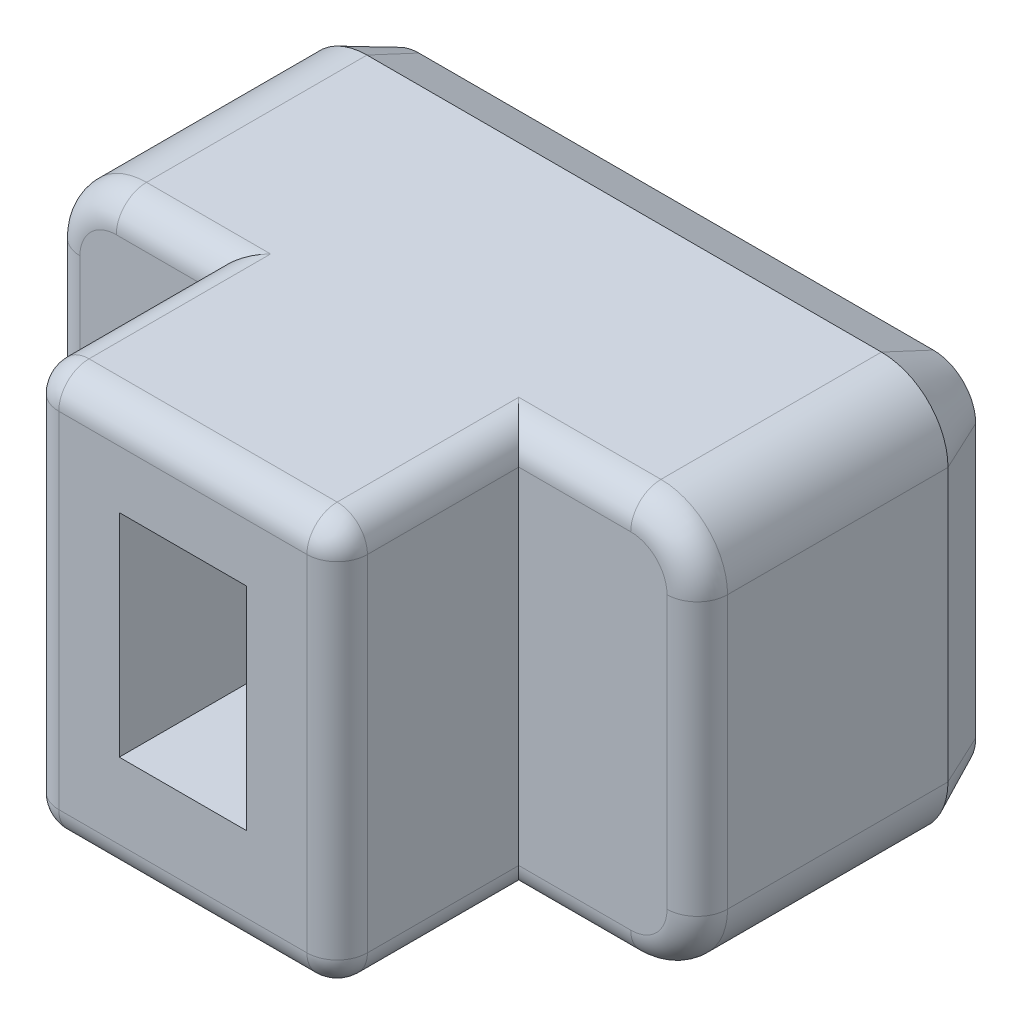
from build123d import *

# Parameters (mm, degrees)
BOSS_EXTRU_1_DEPTH      = 8
ESQUISSE3_W             = 2.1
ESQUISSE3_H             = 3.5
ENL_V_MAT_EXTRU_1_DEPTH = 3
ESQUISSE4_OUTSIDE_W     = 15.69
ESQUISSE4_OUTSIDE_H     = 11.69
ESQUISSE4_OUTSIDE_W_2   = 5.1
ESQUISSE4_OUTSIDE_H_2   = 6.7
ENL_V_MAT_EXTRU_2_DEPTH = 3
CONG_1_R                = 0.5
CHANFREIN1_SIZE         = 0.4
CHANFREIN1_SIZE2        = 0.857802768
ENL_V_MAT_EXTRU_3_DEPTH = 0.2
BOSS_EXTRU_2_DEPTH      = 0.2
BOSS_EXTRU_2_2_DEPTH    = 0.2
BOSS_EXTRU_2_3_DEPTH    = 0.2


with BuildPart() as part:
    # Esquisse2 → Boss.-Extru.1 (new body)
    with BuildSketch(Plane.XY):
        with BuildLine():
            Line((1.1, 0), (9.6, 0))
            ThreePointArc((9.6, 0), (10.377817459, 0.322182541), (10.7, 1.1))
            Line((10.7, 1.1), (10.7, 5.6))
            ThreePointArc((10.7, 5.6), (10.377817459, 6.377817459), (9.6, 6.7))
            Line((9.6, 6.7), (1.1, 6.7))
            ThreePointArc((1.1, 6.7), (0.322182541, 6.377817459), (0, 5.6))
            Line((0, 5.6), (0, 1.1))
            ThreePointArc((0, 1.1), (0.322182541, 0.322182541), (1.1, 0))
        make_face()
    extrude(amount=BOSS_EXTRU_1_DEPTH)

    # Esquisse3 → Enlèv. mat.-Extru.1 (cut)
    with BuildSketch(Plane.XY.offset(8)):
        with Locations((5.2, 3.5)):
            Rectangle(ESQUISSE3_W, ESQUISSE3_H)
    extrude(amount=-ENL_V_MAT_EXTRU_1_DEPTH, mode=Mode.SUBTRACT)

    # Esquisse4 outside → Enlèv. mat.-Extru.2 (cut)
    with BuildSketch(Plane.XY.offset(8)):
        with Locations((5.35, 3.35)):
            Rectangle(ESQUISSE4_OUTSIDE_W, ESQUISSE4_OUTSIDE_H)
        with Locations((5.2, 3.35)):
            Rectangle(ESQUISSE4_OUTSIDE_W_2, ESQUISSE4_OUTSIDE_H_2, mode=Mode.SUBTRACT)
    extrude(amount=-ENL_V_MAT_EXTRU_2_DEPTH, mode=Mode.SUBTRACT)

    # Congé1
    cong_1_edges = [part.edges().sort_by_distance(p)[0] for p in [
        (8.675, 0, 5),
        (10.377817459, 0.322182541, 5),
        (10.7, 3.35, 5),
        (10.377817459, 6.377817459, 5),
        (1.875, 6.7, 5),
        (0.322182541, 6.377817459, 5),
        (1.875, 0, 5),
        (0.322182541, 0.322182541, 5),
        (7.75, 6.7, 6.5),
        (2.65, 6.7, 6.5),
        (7.75, 0, 6.5),
        (2.65, 0, 6.5),
        (2.65, 3.35, 8),
        (5.2, 6.7, 8),
        (7.75, 3.35, 8),
        (5.2, 0, 8),
        (8.675, 6.7, 5),
        (0, 3.35, 5),
    ]]
    fillet(cong_1_edges, radius=CONG_1_R)

    # Chanfrein1
    chanfrein1_edges = [part.edges().sort_by_distance(p)[0] for p in [
        (5.35, 0, 0),
        (10.377817459, 0.322182541, 0),
        (0.322182541, 0.322182541, 0),
        (10.7, 3.35, 0),
        (0, 3.35, 0),
        (10.377817459, 6.377817459, 0),
        (0.322182541, 6.377817459, 0),
        (5.35, 6.7, 0),
    ]]
    chanfrein1_side = [part.faces().sort_by_distance(p)[0] for p in [
        (5.35, 3.35, 0),
    ]]
    chamfer(chanfrein1_edges, length=CHANFREIN1_SIZE, length2=CHANFREIN1_SIZE2, reference=chanfrein1_side[0])

    # Esquisse5 → Enlèv. mat.-Extru.3 (cut)
    # profile 1 of 3: a face of its own
    with BuildSketch(Plane.XY):
        with BuildLine():
            add(Edge.make_bspline(
                [(4.369883856, 3.345323967), (4.368813227, 3.410220828), (4.366709631, 3.537731584), (4.346611401, 3.724706106), (4.315397475, 3.903896521), (4.270277148, 4.074043652), (4.214340316, 4.234867614), (4.145398671, 4.384037783), (4.067839771, 4.523027282), (3.977033045, 4.64884802), (3.877234147, 4.763460778), (3.766783654, 4.86465433), (3.646348249, 4.952148406), (3.516567888, 5.026128704), (3.377499423, 5.085153386), (3.23014263, 5.128172016), (3.074642666, 5.153177552), (2.968475155, 5.156439228), (2.914392271, 5.158100761)],
                knots=[0, 0, 0, 0, 1.195144352, 2.348245511, 3.460097322, 4.542876954, 5.587478219, 6.592632067, 7.566624142, 8.51487101, 9.445639952, 10.361865309, 11.268098707, 12.182468178, 13.107953852, 14.044738146, 15.003968361, 16, 16, 16, 16], degree=3))
            add(Edge.make_bspline(
                [(2.914392271, 5.158100761), (2.858503939, 5.156442095), (2.749000584, 5.15319223), (2.58911106, 5.128325275), (2.438563184, 5.085456576), (2.297551178, 5.026093738), (2.166331241, 4.952363862), (2.045054972, 4.864856392), (1.934590737, 4.763621498), (1.835308413, 4.649088668), (1.746580653, 4.522455836), (1.668059352, 4.384679404), (1.602624479, 4.234346876), (1.546419096, 4.074225408), (1.503890325, 3.903618271), (1.471688338, 3.724799052), (1.453085955, 3.537667095), (1.45077621, 3.41020789), (1.44960042, 3.345323967)],
                knots=[0, 0, 0, 0, 1.024070166, 2.006485348, 2.956709171, 3.886215782, 4.804181762, 5.709643439, 6.621212706, 7.544135401, 8.482081823, 9.451124249, 10.445335459, 11.483063107, 12.557965142, 13.664166725, 14.810929153, 16, 16, 16, 16], degree=3))
            add(Edge.make_bspline(
                [(1.44960042, 3.345323967), (1.450681706, 3.27991297), (1.452802251, 3.15163338), (1.472673532, 2.963545193), (1.504850674, 2.783610957), (1.550947225, 2.612865811), (1.606490699, 2.451322043), (1.675624603, 2.301941529), (1.753431271, 2.162884409), (1.843537024, 2.03675055), (1.943302105, 1.922293635), (2.053460716, 1.821322753), (2.174248749, 1.733720921), (2.304118559, 1.659234354), (2.44361916, 1.599706154), (2.591829693, 1.558097246), (2.748179984, 1.532703821), (2.855134899, 1.52952171), (2.909742138, 1.527897041)],
                knots=[0, 0, 0, 0, 1.200815508, 2.354957547, 3.468772541, 4.553900434, 5.599644995, 6.601592885, 7.572478393, 8.521561906, 9.44266753, 10.355970568, 11.259313516, 12.177237418, 13.099771236, 14.036815551, 14.997670343, 16, 16, 16, 16], degree=3))
            add(Edge.make_bspline(
                [(2.909742138, 1.527897041), (2.965380049, 1.529517802), (3.074129715, 1.532685735), (3.2328265, 1.557982475), (3.382777287, 1.599763578), (3.523547932, 1.658838184), (3.6537362, 1.733766772), (3.774577817, 1.821294574), (3.884614437, 1.922361439), (3.984625613, 2.036278266), (4.072817135, 2.163241667), (4.150337738, 2.301721239), (4.217282836, 2.451617532), (4.272956083, 2.612606076), (4.315623289, 2.783922075), (4.347785722, 2.963532044), (4.366426284, 3.151688757), (4.368716047, 3.279922883), (4.369883856, 3.345323967)],
                knots=[0, 0, 0, 0, 1.019197321, 1.992119517, 2.93636417, 3.865739406, 4.781791275, 5.683291926, 6.594732354, 7.513959455, 8.45564896, 9.422226809, 10.418223395, 11.460277027, 12.539615728, 13.65032206, 14.80163346, 16, 16, 16, 16], degree=3))
        make_face()
        with BuildLine():
            add(Edge.make_bspline(
                [(3.96997243, 3.345323967), (3.96884926, 3.288201422), (3.966670176, 3.177376975), (3.952204476, 3.016195737), (3.926755898, 2.86537907), (3.891193452, 2.725247869), (3.847212338, 2.595729132), (3.794264836, 2.477698567), (3.734676574, 2.369961728), (3.667419516, 2.273054141), (3.591312135, 2.188749315), (3.510932363, 2.113066055), (3.422442429, 2.050270049), (3.32850521, 1.997817016), (3.229014209, 1.958060987), (3.126151531, 1.927830469), (3.019068777, 1.910779812), (2.946483152, 1.908192501), (2.909742138, 1.906882869)],
                knots=[0, 0, 0, 0, 1.368394323, 2.654845707, 3.872704562, 5.028472935, 6.11467807, 7.145207783, 8.123202714, 9.06064659, 9.963649346, 10.839567245, 11.70000047, 12.555970838, 13.411001045, 14.26108962, 15.119807391, 16, 16, 16, 16], degree=3))
            add(Edge.make_bspline(
                [(2.909742138, 1.906882869), (2.873000037, 1.908189938), (2.800412265, 1.910772185), (2.693345263, 1.927859984), (2.590653538, 1.957883931), (2.491594484, 1.998038294), (2.397758207, 2.050195689), (2.30935871, 2.113371654), (2.228089495, 2.188174045), (2.153024942, 2.273620364), (2.084629, 2.369641486), (2.02529171, 2.47775323), (1.972251, 2.595713296), (1.928296957, 2.725252507), (1.892726596, 2.865377721), (1.867280316, 3.016196126), (1.852813958, 3.177376868), (1.850634968, 3.288201386), (1.849511846, 3.345323967)],
                knots=[0, 0, 0, 0, 0.880286533, 1.739095935, 2.58927522, 3.438665601, 4.294727307, 5.155252347, 6.035821703, 6.93481807, 7.87593048, 8.85402977, 9.884669447, 10.970990489, 12.126882191, 13.344871001, 14.631459659, 16, 16, 16, 16], degree=3))
            add(Edge.make_bspline(
                [(1.849511846, 3.345323967), (1.85054818, 3.402455402), (1.852563896, 3.51357852), (1.868249109, 3.674663508), (1.8932339, 3.825396976), (1.929961093, 3.964898592), (1.974742001, 4.093998133), (2.027353528, 4.212000402), (2.087191546, 4.319590148), (2.155365092, 4.415442486), (2.230149126, 4.500969184), (2.311989392, 4.574847399), (2.399828858, 4.63831116), (2.494354784, 4.689467536), (2.593392372, 4.729794657), (2.696830896, 4.758724401), (2.804252878, 4.776248429), (2.877383718, 4.778151743), (2.914392271, 4.779114933)],
                knots=[0, 0, 0, 0, 1.368396896, 2.661591313, 3.873351804, 5.024673231, 6.112906013, 7.143437663, 8.116034728, 9.057048494, 9.955950632, 10.832263623, 11.692698467, 12.545689711, 13.400721526, 14.249120469, 15.113950864, 16, 16, 16, 16], degree=3))
            add(Edge.make_bspline(
                [(2.914392271, 4.779114933), (2.950883964, 4.77814006), (3.023242204, 4.776207016), (3.129636147, 4.758721508), (3.23231397, 4.729800545), (3.330538759, 4.689415456), (3.424266639, 4.638563902), (3.510742002, 4.574335653), (3.592438045, 4.501002863), (3.667288004, 4.415664638), (3.734511991, 4.31933282), (3.794467771, 4.212021946), (3.847191041, 4.094131189), (3.891075337, 3.9648541), (3.926768538, 3.825280687), (3.95232219, 3.674724962), (3.966624194, 3.513524381), (3.968835362, 3.402445207), (3.96997243, 3.345323967)],
                knots=[0, 0, 0, 0, 0.876608953, 1.738200557, 2.583459865, 3.435601933, 4.286000196, 5.139250103, 6.018494159, 6.920402916, 7.860984094, 8.836834272, 9.870812812, 10.960653102, 12.114272321, 13.330085871, 14.627026132, 16, 16, 16, 16], degree=3))
        make_face(mode=Mode.SUBTRACT)
    # profile 2 of 3: a face of its own
    with BuildSketch(Plane.XY):
        with BuildLine():
            add(Edge.make_bspline(
                [(6.294728852, 3.282547174), (6.318323982, 3.287078083), (6.364650687, 3.295974074), (6.431521219, 3.315538485), (6.494700414, 3.339755345), (6.554370583, 3.368026632), (6.609828754, 3.40200557), (6.661924121, 3.439545463), (6.709125772, 3.482717248), (6.753001082, 3.52916027), (6.792040724, 3.580813296), (6.826023201, 3.637211402), (6.854575667, 3.698508206), (6.879766627, 3.763538022), (6.898895542, 3.833671789), (6.913037581, 3.908273638), (6.920390015, 3.987671197), (6.921782221, 4.042056008), (6.922496788, 4.069969672)],
                knots=[0, 0, 0, 0, 1.039557694, 2.041068696, 3.010926647, 3.966234605, 4.894454937, 5.822675269, 6.741144548, 7.658932823, 8.584860084, 9.538005746, 10.503405151, 11.508592806, 12.553130662, 13.645364566, 14.791454829, 16, 16, 16, 16], degree=3))
            add(Edge.make_bspline(
                [(6.922496788, 4.069969672), (6.920587057, 4.112165235), (6.916657333, 4.198992626), (6.89244803, 4.330616405), (6.849156929, 4.463168248), (6.796064053, 4.570577181), (6.741372392, 4.652167528), (6.695524385, 4.712664159), (6.642460696, 4.769538758), (6.584812988, 4.824935562), (6.51939421, 4.876038129), (6.447006637, 4.922900152), (6.366813298, 4.96390077), (6.309906449, 4.986750483), (6.280778453, 4.998446199)],
                knots=[0, 0, 0, 0, 1.262169839, 2.597214165, 3.987364644, 5.42122417, 6.162619332, 6.922894668, 7.688411995, 8.486304344, 9.311628189, 10.166682751, 11.061609327, 12, 12, 12, 12], degree=3))
            add(Edge.make_bspline(
                [(6.280778453, 4.998446199), (6.232035888, 5.014745638), (6.131215212, 5.048459918), (5.996397012, 5.070022183), (5.879749141, 5.082320352), (5.782237066, 5.088050051), (5.676295187, 5.092061115), (5.602897036, 5.092677682), (5.564657993, 5.092998901)],
                knots=[0, 0, 0, 0, 1.272224456, 2.631509649, 3.371988484, 4.180539351, 5.052095566, 6, 6, 6, 6], degree=3))
            Line((5.564657993, 5.092998901), (4.760185008, 5.092998901))
            Line((4.760185008, 5.092998901), (4.760185008, 1.592998901))
            Line((4.760185008, 1.592998901), (5.536757196, 1.592998901))
            add(Edge.make_bspline(
                [(5.536757196, 1.592998901), (5.57086192, 1.593046739), (5.635729051, 1.593137728), (5.728484047, 1.596536682), (5.812766122, 1.600853351), (5.889819045, 1.607757454), (5.9606124, 1.617158031), (6.026230495, 1.628169622), (6.087680655, 1.640103967), (6.126859617, 1.65064587), (6.1459246, 1.655775695)],
                knots=[0, 0, 0, 0, 1.33236813, 2.534162078, 3.625931115, 4.629299164, 5.555750896, 6.415292179, 7.228860962, 8, 8, 8, 8], degree=3))
            add(Edge.make_bspline(
                [(6.1459246, 1.655775695), (6.19297737, 1.672026596), (6.285658954, 1.704036601), (6.392507025, 1.762662009), (6.470484053, 1.816539226), (6.52254804, 1.862102286), (6.572424814, 1.909109707), (6.616154522, 1.961308913), (6.656059231, 2.01657347), (6.69126254, 2.075520948), (6.720098821, 2.138809848), (6.746545766, 2.204576036), (6.76541619, 2.274637216), (6.77931892, 2.347433716), (6.788104034, 2.42309506), (6.789339513, 2.474433804), (6.789968002, 2.500549831)],
                knots=[0, 0, 0, 0, 1.821757314, 3.588382945, 4.444682079, 5.290872065, 6.121128066, 6.953971212, 7.78163198, 8.617858607, 9.464948542, 10.328232883, 11.212597933, 12.11874062, 13.043003058, 14, 14, 14, 14], degree=3))
            add(Edge.make_bspline(
                [(6.789968002, 2.500549831), (6.788505512, 2.54246582), (6.785627825, 2.624942373), (6.766559593, 2.745775123), (6.73201847, 2.859705204), (6.680273173, 2.965177117), (6.611267631, 3.060640982), (6.540141473, 3.130821955), (6.474104771, 3.179920542), (6.419395221, 3.214764136), (6.359165144, 3.246007761), (6.316575715, 3.263499332), (6.294728852, 3.272471886)],
                knots=[0, 0, 0, 0, 1.279367749, 2.517364972, 3.722042857, 4.899867019, 6.08600249, 7.30154732, 7.932361134, 8.595184829, 9.279379768, 10, 10, 10, 10], degree=3))
            Line((6.294728852, 3.272471886), (6.294728852, 3.282547174))
        make_face()
        with BuildLine():
            add(Edge.make_bspline(
                [(5.715787311, 3.107392169), (5.750425656, 3.106820986), (5.814913324, 3.105757591), (5.905398367, 3.097494652), (5.98439068, 3.083112004), (6.032373974, 3.068064024), (6.05524701, 3.060890841)],
                knots=[0, 0, 0, 0, 1.207490432, 2.248035879, 3.164860632, 4, 4, 4, 4], degree=3))
            add(Edge.make_bspline(
                [(6.05524701, 3.060890841), (6.082814077, 3.049372525), (6.136208783, 3.027062675), (6.20699672, 2.979941455), (6.265553327, 2.922962249), (6.312232565, 2.857429705), (6.34737152, 2.784057471), (6.371575423, 2.704550985), (6.388105544, 2.619030581), (6.389392494, 2.559792983), (6.390056576, 2.52922565)],
                knots=[0, 0, 0, 0, 1.06249791, 2.057954283, 3.008138698, 3.958144825, 4.908952983, 5.892770195, 6.912643363, 8, 8, 8, 8], degree=3))
            add(Edge.make_bspline(
                [(6.390056576, 2.52922565), (6.389053196, 2.498414144), (6.387133577, 2.439467002), (6.371525555, 2.35505087), (6.345331381, 2.279399002), (6.308563018, 2.211703961), (6.259243029, 2.153344234), (6.198449857, 2.10338474), (6.126047708, 2.060791084), (6.071900629, 2.040637065), (6.043621678, 2.03011139)],
                knots=[0, 0, 0, 0, 1.124668362, 2.151663266, 3.121418628, 4.037798149, 4.948624099, 5.893271273, 6.899736026, 8, 8, 8, 8], degree=3))
            add(Edge.make_bspline(
                [(6.043621678, 2.03011139), (6.012005367, 2.021122505), (5.944926681, 2.002051253), (5.833490333, 1.987047748), (5.705327739, 1.979125806), (5.613758997, 1.978008829), (5.564657993, 1.977409884)],
                knots=[0, 0, 0, 0, 0.814629318, 1.728356749, 2.781899107, 4, 4, 4, 4], degree=3))
            Line((5.564657993, 1.977409884), (5.139170836, 1.977409884))
            Line((5.139170836, 1.977409884), (5.139170836, 3.107392169))
            Line((5.139170836, 3.107392169), (5.715787311, 3.107392169))
        make_face(mode=Mode.SUBTRACT)
        with BuildLine():
            Line((5.139170836, 3.491803153), (5.139170836, 4.708587918))
            Line((5.139170836, 4.708587918), (5.597208923, 4.708587918))
            add(Edge.make_bspline(
                [(5.597208923, 4.708587918), (5.649418964, 4.707995588), (5.750403846, 4.706849901), (5.873771201, 4.69583027), (5.965027489, 4.682138419), (6.02723509, 4.6706949), (6.084036015, 4.6564299), (6.119650376, 4.643989873), (6.136624335, 4.638060903)],
                knots=[0, 0, 0, 0, 1.719244745, 3.325370432, 4.073828883, 4.758010158, 5.408062281, 6, 6, 6, 6], degree=3))
            add(Edge.make_bspline(
                [(6.136624335, 4.638060903), (6.170061199, 4.624281189), (6.2345191, 4.597717352), (6.317650883, 4.539865672), (6.386430392, 4.475173905), (6.439766675, 4.402962922), (6.478877925, 4.325135992), (6.50511967, 4.24320503), (6.519957537, 4.158612833), (6.521710691, 4.101542759), (6.522585362, 4.07306976)],
                knots=[0, 0, 0, 0, 1.180851053, 2.276385089, 3.293359184, 4.260951527, 5.19900153, 6.132464837, 7.068262524, 8, 8, 8, 8], degree=3))
            add(Edge.make_bspline(
                [(6.522585362, 4.07306976), (6.521489691, 4.040727732), (6.519355222, 3.977722507), (6.504362378, 3.886376689), (6.476270007, 3.802624164), (6.436060773, 3.725931087), (6.378287487, 3.660423688), (6.307311823, 3.602057466), (6.217222836, 3.555866863), (6.149454673, 3.536314279), (6.11337367, 3.525904127)],
                knots=[0, 0, 0, 0, 1.037774006, 2.021678517, 2.957477969, 3.862483003, 4.779555303, 5.740137878, 6.796808297, 8, 8, 8, 8], degree=3))
            add(Edge.make_bspline(
                [(6.11337367, 3.525904127), (6.088645152, 3.520350924), (6.036203834, 3.508574347), (5.949348637, 3.497901914), (5.846819029, 3.493349413), (5.772625966, 3.492349713), (5.732062776, 3.491803153)],
                knots=[0, 0, 0, 0, 0.792135981, 1.679868331, 2.731526387, 4, 4, 4, 4], degree=3))
            Line((5.732062776, 3.491803153), (5.139170836, 3.491803153))
        make_face(mode=Mode.SUBTRACT)
    # profile 3 of 3: a face of its own
    with BuildSketch(Plane.XY):
        with BuildLine():
            add(Edge.make_bspline(
                [(7.598006089, 2.519150362), (7.598390883, 2.543748085), (7.599132286, 2.591141743), (7.610620119, 2.658611592), (7.626776636, 2.720081012), (7.652432663, 2.774107358), (7.683231965, 2.822524502), (7.717725281, 2.867261442), (7.758878122, 2.906041268), (7.8197572, 2.953064911), (7.907038066, 3.003717061), (8.024126068, 3.049957606), (8.150573171, 3.089057507), (8.237345491, 3.113522336), (8.281575619, 3.125992701)],
                knots=[0, 0, 0, 0, 0.880486965, 1.696478074, 2.446944501, 3.151258593, 3.829523831, 4.502012172, 5.170022751, 5.849803385, 7.256908892, 8.768459035, 10.352798764, 12, 12, 12, 12], degree=3))
            add(Edge.make_bspline(
                [(8.281575619, 3.125992701), (8.341582234, 3.143040851), (8.461391365, 3.177079168), (8.609483565, 3.223336728), (8.723944779, 3.267189913), (8.804655968, 3.305887287), (8.880515462, 3.350604981), (8.952056586, 3.400489678), (9.017720106, 3.458307302), (9.076896499, 3.523894814), (9.129769308, 3.597092218), (9.176205637, 3.678501859), (9.214281445, 3.770574703), (9.239635427, 3.874815211), (9.255246146, 3.990961756), (9.25711968, 4.072239826), (9.25810352, 4.114920956)],
                knots=[0, 0, 0, 0, 1.706742266, 3.407679468, 4.242430161, 5.058020634, 5.853204933, 6.649362358, 7.440579056, 8.241210102, 9.061198638, 9.906297875, 10.800118187, 11.777216625, 12.832761325, 14, 14, 14, 14], degree=3))
            add(Edge.make_bspline(
                [(9.25810352, 4.114920956), (9.257193417, 4.158640741), (9.255424976, 4.24359362), (9.238052451, 4.366171328), (9.210402253, 4.479547926), (9.171603315, 4.583782776), (9.121537131, 4.678086074), (9.064038804, 4.764673025), (8.996795253, 4.841689789), (8.921143944, 4.910411115), (8.836929813, 4.970175567), (8.745086255, 5.021337872), (8.645590211, 5.064275045), (8.538797732, 5.098570422), (8.42563185, 5.125952695), (8.306812215, 5.143750956), (8.183147662, 5.15607339), (8.098960647, 5.157416219), (8.056044175, 5.158100761)],
                knots=[0, 0, 0, 0, 1.159127606, 2.252326411, 3.27615946, 4.249869671, 5.193974946, 6.102490449, 7.001157183, 7.898673524, 8.807628291, 9.734160275, 10.682583241, 11.677288198, 12.706154421, 13.767464238, 14.861908121, 16, 16, 16, 16], degree=3))
            add(Edge.make_bspline(
                [(8.056044175, 5.158100761), (8.015187384, 5.157475502), (7.932487543, 5.156209892), (7.808613446, 5.141961731), (7.686258894, 5.12235001), (7.568891637, 5.096693443), (7.459552578, 5.06755058), (7.362619545, 5.032588899), (7.279571042, 4.99836097), (7.232951072, 4.969525727), (7.212045061, 4.956595004)],
                knots=[0, 0, 0, 0, 1.117668173, 2.262316179, 3.408404461, 4.508127461, 5.549289101, 6.501919885, 7.328208939, 8, 8, 8, 8], degree=3))
            Line((7.212045061, 4.956595004), (7.212045061, 4.567533888))
            add(Edge.make_bspline(
                [(7.212045061, 4.567533888), (7.241527483, 4.582997837), (7.302721968, 4.615095215), (7.401589035, 4.655013594), (7.50677455, 4.691364968), (7.616608187, 4.721344229), (7.728746276, 4.745119233), (7.840718769, 4.763351298), (7.949802148, 4.776918423), (8.021388723, 4.778398446), (8.056044175, 4.779114933)],
                knots=[0, 0, 0, 0, 0.909703881, 1.88820511, 2.911196513, 3.951283487, 4.998564079, 6.043603477, 7.052897759, 8, 8, 8, 8], degree=3))
            add(Edge.make_bspline(
                [(8.056044175, 4.779114933), (8.109109392, 4.777783095), (8.213479799, 4.775163592), (8.340858491, 4.753991765), (8.437710139, 4.731200377), (8.504514353, 4.706425596), (8.567636953, 4.678173866), (8.625925414, 4.643993945), (8.679474, 4.604255999), (8.727135226, 4.557469175), (8.768350941, 4.503175419), (8.804235313, 4.442558272), (8.833388524, 4.374497247), (8.853022461, 4.298206668), (8.865729212, 4.214292782), (8.866889453, 4.15553109), (8.86749236, 4.124996244)],
                knots=[0, 0, 0, 0, 1.87034002, 3.678646016, 4.542823419, 5.375882515, 6.187380047, 6.979772314, 7.754358122, 8.534072985, 9.326936712, 10.152133513, 11.013664266, 11.928806421, 12.92372774, 14, 14, 14, 14], degree=3))
            add(Edge.make_bspline(
                [(8.86749236, 4.124996244), (8.866690156, 4.099903198), (8.865161426, 4.052084319), (8.855213948, 3.983297326), (8.837794923, 3.92135971), (8.812417473, 3.865989077), (8.780935811, 3.817013623), (8.744952482, 3.772165029), (8.703882233, 3.732117974), (8.64266626, 3.683737571), (8.554887036, 3.632852992), (8.437081266, 3.58613705), (8.309474542, 3.547390216), (8.221687722, 3.52289006), (8.17694763, 3.510403684)],
                knots=[0, 0, 0, 0, 0.889177509, 1.694472311, 2.456508881, 3.161117673, 3.844288232, 4.514829322, 5.194556335, 5.872245921, 7.275862128, 8.770198597, 10.353948627, 12, 12, 12, 12], degree=3))
            add(Edge.make_bspline(
                [(8.17694763, 3.510403684), (8.11718576, 3.493921983), (7.998354078, 3.461149444), (7.851689286, 3.415770238), (7.738463261, 3.373096155), (7.658548771, 3.335139901), (7.583379763, 3.291295308), (7.512878613, 3.241825996), (7.447041543, 3.186160003), (7.388632001, 3.121984205), (7.337210738, 3.05014798), (7.292899393, 2.970440013), (7.255065676, 2.881629678), (7.230717291, 2.780877948), (7.214893802, 2.669231771), (7.21302301, 2.591030573), (7.212045061, 2.550151248)],
                knots=[0, 0, 0, 0, 1.731440325, 3.44283011, 4.285652068, 5.108629109, 5.910524492, 6.713230969, 7.511482537, 8.313280534, 9.130226032, 9.973295025, 10.856326095, 11.817060712, 12.858878303, 14, 14, 14, 14], degree=3))
            add(Edge.make_bspline(
                [(7.212045061, 2.550151248), (7.213089026, 2.507220521), (7.215108755, 2.424163689), (7.230528564, 2.304132404), (7.256757806, 2.193434966), (7.293320339, 2.091816425), (7.339216102, 1.999626679), (7.3925374, 1.915317032), (7.45344173, 1.839426682), (7.522546609, 1.772300655), (7.597772151, 1.713095973), (7.679763315, 1.662904624), (7.767139481, 1.619471659), (7.861022768, 1.586059495), (7.959052159, 1.559876835), (8.060621798, 1.541135899), (8.165342148, 1.530280641), (8.236341087, 1.528698035), (8.272275353, 1.527897041)],
                knots=[0, 0, 0, 0, 1.234756564, 2.3888477, 3.473975945, 4.501297612, 5.488398123, 6.43058259, 7.366060614, 8.280490487, 9.196278313, 10.114024079, 11.041318885, 11.99816134, 12.975223422, 13.957668963, 14.966327269, 16, 16, 16, 16], degree=3))
            add(Edge.make_bspline(
                [(8.272275353, 1.527897041), (8.313114317, 1.528414894), (8.393372196, 1.529432593), (8.511674691, 1.539768451), (8.625773656, 1.556836295), (8.735698309, 1.580122977), (8.841020404, 1.608613118), (8.941575357, 1.64265071), (9.038188916, 1.678947205), (9.099901215, 1.707582175), (9.130224866, 1.721652577)],
                knots=[0, 0, 0, 0, 1.104714536, 2.171016076, 3.209933901, 4.224369017, 5.209509432, 6.159944183, 7.095849437, 8, 8, 8, 8], degree=3))
            Line((9.130224866, 1.721652577), (9.130224866, 2.116138848))
            add(Edge.make_bspline(
                [(9.130224866, 2.116138848), (9.06533036, 2.08731366), (8.935589525, 2.029684684), (8.766019851, 1.975243545), (8.626850918, 1.939879235), (8.517786007, 1.92322185), (8.405648304, 1.909636109), (8.329412515, 1.907807312), (8.290875885, 1.906882869)],
                knots=[0, 0, 0, 0, 1.464993217, 2.928898808, 3.670070941, 4.426719255, 5.204718158, 6, 6, 6, 6], degree=3))
            add(Edge.make_bspline(
                [(8.290875885, 1.906882869), (8.262448119, 1.907604431), (8.207294133, 1.909004366), (8.127337346, 1.916153316), (8.053383453, 1.930620029), (7.984883964, 1.948563605), (7.922303529, 1.973137211), (7.865108181, 2.001470654), (7.813232536, 2.034247574), (7.767131169, 2.071664837), (7.726544368, 2.113832812), (7.691489383, 2.160336005), (7.662711017, 2.211662553), (7.638594879, 2.266633945), (7.620277765, 2.325442132), (7.606947225, 2.387414195), (7.599152887, 2.452295992), (7.598391988, 2.496653785), (7.598006089, 2.519150362)],
                knots=[0, 0, 0, 0, 1.296243822, 2.514900931, 3.653549349, 4.727708741, 5.738067187, 6.712369634, 7.633630829, 8.529322939, 9.412149162, 10.295368015, 11.176149746, 12.088486272, 13.027046857, 13.978667069, 14.974857196, 16, 16, 16, 16], degree=3))
        make_face()
    extrude(amount=ENL_V_MAT_EXTRU_3_DEPTH, mode=Mode.SUBTRACT)


with BuildPart() as body_2:
    # Esquisse5_4 → Boss.-Extru.2 (new body)
    with BuildSketch(Plane.XY):
        with BuildLine():
            add(Edge.make_bspline(
                [(4.369883856, 3.345323967), (4.368813227, 3.410220828), (4.366709631, 3.537731584), (4.346611401, 3.724706106), (4.315397475, 3.903896521), (4.270277148, 4.074043652), (4.214340316, 4.234867614), (4.145398671, 4.384037783), (4.067839771, 4.523027282), (3.977033045, 4.64884802), (3.877234147, 4.763460778), (3.766783654, 4.86465433), (3.646348249, 4.952148406), (3.516567888, 5.026128704), (3.377499423, 5.085153386), (3.23014263, 5.128172016), (3.074642666, 5.153177552), (2.968475155, 5.156439228), (2.914392271, 5.158100761)],
                knots=[0, 0, 0, 0, 1.195144352, 2.348245511, 3.460097322, 4.542876954, 5.587478219, 6.592632067, 7.566624142, 8.51487101, 9.445639952, 10.361865309, 11.268098707, 12.182468178, 13.107953852, 14.044738146, 15.003968361, 16, 16, 16, 16], degree=3))
            add(Edge.make_bspline(
                [(2.914392271, 5.158100761), (2.858503939, 5.156442095), (2.749000584, 5.15319223), (2.58911106, 5.128325275), (2.438563184, 5.085456576), (2.297551178, 5.026093738), (2.166331241, 4.952363862), (2.045054972, 4.864856392), (1.934590737, 4.763621498), (1.835308413, 4.649088668), (1.746580653, 4.522455836), (1.668059352, 4.384679404), (1.602624479, 4.234346876), (1.546419096, 4.074225408), (1.503890325, 3.903618271), (1.471688338, 3.724799052), (1.453085955, 3.537667095), (1.45077621, 3.41020789), (1.44960042, 3.345323967)],
                knots=[0, 0, 0, 0, 1.024070166, 2.006485348, 2.956709171, 3.886215782, 4.804181762, 5.709643439, 6.621212706, 7.544135401, 8.482081823, 9.451124249, 10.445335459, 11.483063107, 12.557965142, 13.664166725, 14.810929153, 16, 16, 16, 16], degree=3))
            add(Edge.make_bspline(
                [(1.44960042, 3.345323967), (1.450681706, 3.27991297), (1.452802251, 3.15163338), (1.472673532, 2.963545193), (1.504850674, 2.783610957), (1.550947225, 2.612865811), (1.606490699, 2.451322043), (1.675624603, 2.301941529), (1.753431271, 2.162884409), (1.843537024, 2.03675055), (1.943302105, 1.922293635), (2.053460716, 1.821322753), (2.174248749, 1.733720921), (2.304118559, 1.659234354), (2.44361916, 1.599706154), (2.591829693, 1.558097246), (2.748179984, 1.532703821), (2.855134899, 1.52952171), (2.909742138, 1.527897041)],
                knots=[0, 0, 0, 0, 1.200815508, 2.354957547, 3.468772541, 4.553900434, 5.599644995, 6.601592885, 7.572478393, 8.521561906, 9.44266753, 10.355970568, 11.259313516, 12.177237418, 13.099771236, 14.036815551, 14.997670343, 16, 16, 16, 16], degree=3))
            add(Edge.make_bspline(
                [(2.909742138, 1.527897041), (2.965380049, 1.529517802), (3.074129715, 1.532685735), (3.2328265, 1.557982475), (3.382777287, 1.599763578), (3.523547932, 1.658838184), (3.6537362, 1.733766772), (3.774577817, 1.821294574), (3.884614437, 1.922361439), (3.984625613, 2.036278266), (4.072817135, 2.163241667), (4.150337738, 2.301721239), (4.217282836, 2.451617532), (4.272956083, 2.612606076), (4.315623289, 2.783922075), (4.347785722, 2.963532044), (4.366426284, 3.151688757), (4.368716047, 3.279922883), (4.369883856, 3.345323967)],
                knots=[0, 0, 0, 0, 1.019197321, 1.992119517, 2.93636417, 3.865739406, 4.781791275, 5.683291926, 6.594732354, 7.513959455, 8.45564896, 9.422226809, 10.418223395, 11.460277027, 12.539615728, 13.65032206, 14.80163346, 16, 16, 16, 16], degree=3))
        make_face()
        with BuildLine():
            add(Edge.make_bspline(
                [(3.96997243, 3.345323967), (3.96884926, 3.288201422), (3.966670176, 3.177376975), (3.952204476, 3.016195737), (3.926755898, 2.86537907), (3.891193452, 2.725247869), (3.847212338, 2.595729132), (3.794264836, 2.477698567), (3.734676574, 2.369961728), (3.667419516, 2.273054141), (3.591312135, 2.188749315), (3.510932363, 2.113066055), (3.422442429, 2.050270049), (3.32850521, 1.997817016), (3.229014209, 1.958060987), (3.126151531, 1.927830469), (3.019068777, 1.910779812), (2.946483152, 1.908192501), (2.909742138, 1.906882869)],
                knots=[0, 0, 0, 0, 1.368394323, 2.654845707, 3.872704562, 5.028472935, 6.11467807, 7.145207783, 8.123202714, 9.06064659, 9.963649346, 10.839567245, 11.70000047, 12.555970838, 13.411001045, 14.26108962, 15.119807391, 16, 16, 16, 16], degree=3))
            add(Edge.make_bspline(
                [(2.909742138, 1.906882869), (2.873000037, 1.908189938), (2.800412265, 1.910772185), (2.693345263, 1.927859984), (2.590653538, 1.957883931), (2.491594484, 1.998038294), (2.397758207, 2.050195689), (2.30935871, 2.113371654), (2.228089495, 2.188174045), (2.153024942, 2.273620364), (2.084629, 2.369641486), (2.02529171, 2.47775323), (1.972251, 2.595713296), (1.928296957, 2.725252507), (1.892726596, 2.865377721), (1.867280316, 3.016196126), (1.852813958, 3.177376868), (1.850634968, 3.288201386), (1.849511846, 3.345323967)],
                knots=[0, 0, 0, 0, 0.880286533, 1.739095935, 2.58927522, 3.438665601, 4.294727307, 5.155252347, 6.035821703, 6.93481807, 7.87593048, 8.85402977, 9.884669447, 10.970990489, 12.126882191, 13.344871001, 14.631459659, 16, 16, 16, 16], degree=3))
            add(Edge.make_bspline(
                [(1.849511846, 3.345323967), (1.85054818, 3.402455402), (1.852563896, 3.51357852), (1.868249109, 3.674663508), (1.8932339, 3.825396976), (1.929961093, 3.964898592), (1.974742001, 4.093998133), (2.027353528, 4.212000402), (2.087191546, 4.319590148), (2.155365092, 4.415442486), (2.230149126, 4.500969184), (2.311989392, 4.574847399), (2.399828858, 4.63831116), (2.494354784, 4.689467536), (2.593392372, 4.729794657), (2.696830896, 4.758724401), (2.804252878, 4.776248429), (2.877383718, 4.778151743), (2.914392271, 4.779114933)],
                knots=[0, 0, 0, 0, 1.368396896, 2.661591313, 3.873351804, 5.024673231, 6.112906013, 7.143437663, 8.116034728, 9.057048494, 9.955950632, 10.832263623, 11.692698467, 12.545689711, 13.400721526, 14.249120469, 15.113950864, 16, 16, 16, 16], degree=3))
            add(Edge.make_bspline(
                [(2.914392271, 4.779114933), (2.950883964, 4.77814006), (3.023242204, 4.776207016), (3.129636147, 4.758721508), (3.23231397, 4.729800545), (3.330538759, 4.689415456), (3.424266639, 4.638563902), (3.510742002, 4.574335653), (3.592438045, 4.501002863), (3.667288004, 4.415664638), (3.734511991, 4.31933282), (3.794467771, 4.212021946), (3.847191041, 4.094131189), (3.891075337, 3.9648541), (3.926768538, 3.825280687), (3.95232219, 3.674724962), (3.966624194, 3.513524381), (3.968835362, 3.402445207), (3.96997243, 3.345323967)],
                knots=[0, 0, 0, 0, 0.876608953, 1.738200557, 2.583459865, 3.435601933, 4.286000196, 5.139250103, 6.018494159, 6.920402916, 7.860984094, 8.836834272, 9.870812812, 10.960653102, 12.114272321, 13.330085871, 14.627026132, 16, 16, 16, 16], degree=3))
        make_face(mode=Mode.SUBTRACT)
    extrude(amount=-BOSS_EXTRU_2_DEPTH)


with BuildPart() as body_3:
    # Esquisse5_4 → Boss.-Extru.2 2 (new body)
    with BuildSketch(Plane.XY):
        with BuildLine():
            add(Edge.make_bspline(
                [(6.294728852, 3.282547174), (6.318323982, 3.287078083), (6.364650687, 3.295974074), (6.431521219, 3.315538485), (6.494700414, 3.339755345), (6.554370583, 3.368026632), (6.609828754, 3.40200557), (6.661924121, 3.439545463), (6.709125772, 3.482717248), (6.753001082, 3.52916027), (6.792040724, 3.580813296), (6.826023201, 3.637211402), (6.854575667, 3.698508206), (6.879766627, 3.763538022), (6.898895542, 3.833671789), (6.913037581, 3.908273638), (6.920390015, 3.987671197), (6.921782221, 4.042056008), (6.922496788, 4.069969672)],
                knots=[0, 0, 0, 0, 1.039557694, 2.041068696, 3.010926647, 3.966234605, 4.894454937, 5.822675269, 6.741144548, 7.658932823, 8.584860084, 9.538005746, 10.503405151, 11.508592806, 12.553130662, 13.645364566, 14.791454829, 16, 16, 16, 16], degree=3))
            add(Edge.make_bspline(
                [(6.922496788, 4.069969672), (6.920587057, 4.112165235), (6.916657333, 4.198992626), (6.89244803, 4.330616405), (6.849156929, 4.463168248), (6.796064053, 4.570577181), (6.741372392, 4.652167528), (6.695524385, 4.712664159), (6.642460696, 4.769538758), (6.584812988, 4.824935562), (6.51939421, 4.876038129), (6.447006637, 4.922900152), (6.366813298, 4.96390077), (6.309906449, 4.986750483), (6.280778453, 4.998446199)],
                knots=[0, 0, 0, 0, 1.262169839, 2.597214165, 3.987364644, 5.42122417, 6.162619332, 6.922894668, 7.688411995, 8.486304344, 9.311628189, 10.166682751, 11.061609327, 12, 12, 12, 12], degree=3))
            add(Edge.make_bspline(
                [(6.280778453, 4.998446199), (6.232035888, 5.014745638), (6.131215212, 5.048459918), (5.996397012, 5.070022183), (5.879749141, 5.082320352), (5.782237066, 5.088050051), (5.676295187, 5.092061115), (5.602897036, 5.092677682), (5.564657993, 5.092998901)],
                knots=[0, 0, 0, 0, 1.272224456, 2.631509649, 3.371988484, 4.180539351, 5.052095566, 6, 6, 6, 6], degree=3))
            Line((5.564657993, 5.092998901), (4.760185008, 5.092998901))
            Line((4.760185008, 5.092998901), (4.760185008, 1.592998901))
            Line((4.760185008, 1.592998901), (5.536757196, 1.592998901))
            add(Edge.make_bspline(
                [(5.536757196, 1.592998901), (5.57086192, 1.593046739), (5.635729051, 1.593137728), (5.728484047, 1.596536682), (5.812766122, 1.600853351), (5.889819045, 1.607757454), (5.9606124, 1.617158031), (6.026230495, 1.628169622), (6.087680655, 1.640103967), (6.126859617, 1.65064587), (6.1459246, 1.655775695)],
                knots=[0, 0, 0, 0, 1.33236813, 2.534162078, 3.625931115, 4.629299164, 5.555750896, 6.415292179, 7.228860962, 8, 8, 8, 8], degree=3))
            add(Edge.make_bspline(
                [(6.1459246, 1.655775695), (6.19297737, 1.672026596), (6.285658954, 1.704036601), (6.392507025, 1.762662009), (6.470484053, 1.816539226), (6.52254804, 1.862102286), (6.572424814, 1.909109707), (6.616154522, 1.961308913), (6.656059231, 2.01657347), (6.69126254, 2.075520948), (6.720098821, 2.138809848), (6.746545766, 2.204576036), (6.76541619, 2.274637216), (6.77931892, 2.347433716), (6.788104034, 2.42309506), (6.789339513, 2.474433804), (6.789968002, 2.500549831)],
                knots=[0, 0, 0, 0, 1.821757314, 3.588382945, 4.444682079, 5.290872065, 6.121128066, 6.953971212, 7.78163198, 8.617858607, 9.464948542, 10.328232883, 11.212597933, 12.11874062, 13.043003058, 14, 14, 14, 14], degree=3))
            add(Edge.make_bspline(
                [(6.789968002, 2.500549831), (6.788505512, 2.54246582), (6.785627825, 2.624942373), (6.766559593, 2.745775123), (6.73201847, 2.859705204), (6.680273173, 2.965177117), (6.611267631, 3.060640982), (6.540141473, 3.130821955), (6.474104771, 3.179920542), (6.419395221, 3.214764136), (6.359165144, 3.246007761), (6.316575715, 3.263499332), (6.294728852, 3.272471886)],
                knots=[0, 0, 0, 0, 1.279367749, 2.517364972, 3.722042857, 4.899867019, 6.08600249, 7.30154732, 7.932361134, 8.595184829, 9.279379768, 10, 10, 10, 10], degree=3))
            Line((6.294728852, 3.272471886), (6.294728852, 3.282547174))
        make_face()
        with BuildLine():
            add(Edge.make_bspline(
                [(5.715787311, 3.107392169), (5.750425656, 3.106820986), (5.814913324, 3.105757591), (5.905398367, 3.097494652), (5.98439068, 3.083112004), (6.032373974, 3.068064024), (6.05524701, 3.060890841)],
                knots=[0, 0, 0, 0, 1.207490432, 2.248035879, 3.164860632, 4, 4, 4, 4], degree=3))
            add(Edge.make_bspline(
                [(6.05524701, 3.060890841), (6.082814077, 3.049372525), (6.136208783, 3.027062675), (6.20699672, 2.979941455), (6.265553327, 2.922962249), (6.312232565, 2.857429705), (6.34737152, 2.784057471), (6.371575423, 2.704550985), (6.388105544, 2.619030581), (6.389392494, 2.559792983), (6.390056576, 2.52922565)],
                knots=[0, 0, 0, 0, 1.06249791, 2.057954283, 3.008138698, 3.958144825, 4.908952983, 5.892770195, 6.912643363, 8, 8, 8, 8], degree=3))
            add(Edge.make_bspline(
                [(6.390056576, 2.52922565), (6.389053196, 2.498414144), (6.387133577, 2.439467002), (6.371525555, 2.35505087), (6.345331381, 2.279399002), (6.308563018, 2.211703961), (6.259243029, 2.153344234), (6.198449857, 2.10338474), (6.126047708, 2.060791084), (6.071900629, 2.040637065), (6.043621678, 2.03011139)],
                knots=[0, 0, 0, 0, 1.124668362, 2.151663266, 3.121418628, 4.037798149, 4.948624099, 5.893271273, 6.899736026, 8, 8, 8, 8], degree=3))
            add(Edge.make_bspline(
                [(6.043621678, 2.03011139), (6.012005367, 2.021122505), (5.944926681, 2.002051253), (5.833490333, 1.987047748), (5.705327739, 1.979125806), (5.613758997, 1.978008829), (5.564657993, 1.977409884)],
                knots=[0, 0, 0, 0, 0.814629318, 1.728356749, 2.781899107, 4, 4, 4, 4], degree=3))
            Line((5.564657993, 1.977409884), (5.139170836, 1.977409884))
            Line((5.139170836, 1.977409884), (5.139170836, 3.107392169))
            Line((5.139170836, 3.107392169), (5.715787311, 3.107392169))
        make_face(mode=Mode.SUBTRACT)
        with BuildLine():
            Line((5.139170836, 3.491803153), (5.139170836, 4.708587918))
            Line((5.139170836, 4.708587918), (5.597208923, 4.708587918))
            add(Edge.make_bspline(
                [(5.597208923, 4.708587918), (5.649418964, 4.707995588), (5.750403846, 4.706849901), (5.873771201, 4.69583027), (5.965027489, 4.682138419), (6.02723509, 4.6706949), (6.084036015, 4.6564299), (6.119650376, 4.643989873), (6.136624335, 4.638060903)],
                knots=[0, 0, 0, 0, 1.719244745, 3.325370432, 4.073828883, 4.758010158, 5.408062281, 6, 6, 6, 6], degree=3))
            add(Edge.make_bspline(
                [(6.136624335, 4.638060903), (6.170061199, 4.624281189), (6.2345191, 4.597717352), (6.317650883, 4.539865672), (6.386430392, 4.475173905), (6.439766675, 4.402962922), (6.478877925, 4.325135992), (6.50511967, 4.24320503), (6.519957537, 4.158612833), (6.521710691, 4.101542759), (6.522585362, 4.07306976)],
                knots=[0, 0, 0, 0, 1.180851053, 2.276385089, 3.293359184, 4.260951527, 5.19900153, 6.132464837, 7.068262524, 8, 8, 8, 8], degree=3))
            add(Edge.make_bspline(
                [(6.522585362, 4.07306976), (6.521489691, 4.040727732), (6.519355222, 3.977722507), (6.504362378, 3.886376689), (6.476270007, 3.802624164), (6.436060773, 3.725931087), (6.378287487, 3.660423688), (6.307311823, 3.602057466), (6.217222836, 3.555866863), (6.149454673, 3.536314279), (6.11337367, 3.525904127)],
                knots=[0, 0, 0, 0, 1.037774006, 2.021678517, 2.957477969, 3.862483003, 4.779555303, 5.740137878, 6.796808297, 8, 8, 8, 8], degree=3))
            add(Edge.make_bspline(
                [(6.11337367, 3.525904127), (6.088645152, 3.520350924), (6.036203834, 3.508574347), (5.949348637, 3.497901914), (5.846819029, 3.493349413), (5.772625966, 3.492349713), (5.732062776, 3.491803153)],
                knots=[0, 0, 0, 0, 0.792135981, 1.679868331, 2.731526387, 4, 4, 4, 4], degree=3))
            Line((5.732062776, 3.491803153), (5.139170836, 3.491803153))
        make_face(mode=Mode.SUBTRACT)
    extrude(amount=-BOSS_EXTRU_2_2_DEPTH)


with BuildPart() as body_4:
    # Esquisse5_4 → Boss.-Extru.2 3 (new body)
    with BuildSketch(Plane.XY):
        with BuildLine():
            add(Edge.make_bspline(
                [(7.598006089, 2.519150362), (7.598390883, 2.543748085), (7.599132286, 2.591141743), (7.610620119, 2.658611592), (7.626776636, 2.720081012), (7.652432663, 2.774107358), (7.683231965, 2.822524502), (7.717725281, 2.867261442), (7.758878122, 2.906041268), (7.8197572, 2.953064911), (7.907038066, 3.003717061), (8.024126068, 3.049957606), (8.150573171, 3.089057507), (8.237345491, 3.113522336), (8.281575619, 3.125992701)],
                knots=[0, 0, 0, 0, 0.880486965, 1.696478074, 2.446944501, 3.151258593, 3.829523831, 4.502012172, 5.170022751, 5.849803385, 7.256908892, 8.768459035, 10.352798764, 12, 12, 12, 12], degree=3))
            add(Edge.make_bspline(
                [(8.281575619, 3.125992701), (8.341582234, 3.143040851), (8.461391365, 3.177079168), (8.609483565, 3.223336728), (8.723944779, 3.267189913), (8.804655968, 3.305887287), (8.880515462, 3.350604981), (8.952056586, 3.400489678), (9.017720106, 3.458307302), (9.076896499, 3.523894814), (9.129769308, 3.597092218), (9.176205637, 3.678501859), (9.214281445, 3.770574703), (9.239635427, 3.874815211), (9.255246146, 3.990961756), (9.25711968, 4.072239826), (9.25810352, 4.114920956)],
                knots=[0, 0, 0, 0, 1.706742266, 3.407679468, 4.242430161, 5.058020634, 5.853204933, 6.649362358, 7.440579056, 8.241210102, 9.061198638, 9.906297875, 10.800118187, 11.777216625, 12.832761325, 14, 14, 14, 14], degree=3))
            add(Edge.make_bspline(
                [(9.25810352, 4.114920956), (9.257193417, 4.158640741), (9.255424976, 4.24359362), (9.238052451, 4.366171328), (9.210402253, 4.479547926), (9.171603315, 4.583782776), (9.121537131, 4.678086074), (9.064038804, 4.764673025), (8.996795253, 4.841689789), (8.921143944, 4.910411115), (8.836929813, 4.970175567), (8.745086255, 5.021337872), (8.645590211, 5.064275045), (8.538797732, 5.098570422), (8.42563185, 5.125952695), (8.306812215, 5.143750956), (8.183147662, 5.15607339), (8.098960647, 5.157416219), (8.056044175, 5.158100761)],
                knots=[0, 0, 0, 0, 1.159127606, 2.252326411, 3.27615946, 4.249869671, 5.193974946, 6.102490449, 7.001157183, 7.898673524, 8.807628291, 9.734160275, 10.682583241, 11.677288198, 12.706154421, 13.767464238, 14.861908121, 16, 16, 16, 16], degree=3))
            add(Edge.make_bspline(
                [(8.056044175, 5.158100761), (8.015187384, 5.157475502), (7.932487543, 5.156209892), (7.808613446, 5.141961731), (7.686258894, 5.12235001), (7.568891637, 5.096693443), (7.459552578, 5.06755058), (7.362619545, 5.032588899), (7.279571042, 4.99836097), (7.232951072, 4.969525727), (7.212045061, 4.956595004)],
                knots=[0, 0, 0, 0, 1.117668173, 2.262316179, 3.408404461, 4.508127461, 5.549289101, 6.501919885, 7.328208939, 8, 8, 8, 8], degree=3))
            Line((7.212045061, 4.956595004), (7.212045061, 4.567533888))
            add(Edge.make_bspline(
                [(7.212045061, 4.567533888), (7.241527483, 4.582997837), (7.302721968, 4.615095215), (7.401589035, 4.655013594), (7.50677455, 4.691364968), (7.616608187, 4.721344229), (7.728746276, 4.745119233), (7.840718769, 4.763351298), (7.949802148, 4.776918423), (8.021388723, 4.778398446), (8.056044175, 4.779114933)],
                knots=[0, 0, 0, 0, 0.909703881, 1.88820511, 2.911196513, 3.951283487, 4.998564079, 6.043603477, 7.052897759, 8, 8, 8, 8], degree=3))
            add(Edge.make_bspline(
                [(8.056044175, 4.779114933), (8.109109392, 4.777783095), (8.213479799, 4.775163592), (8.340858491, 4.753991765), (8.437710139, 4.731200377), (8.504514353, 4.706425596), (8.567636953, 4.678173866), (8.625925414, 4.643993945), (8.679474, 4.604255999), (8.727135226, 4.557469175), (8.768350941, 4.503175419), (8.804235313, 4.442558272), (8.833388524, 4.374497247), (8.853022461, 4.298206668), (8.865729212, 4.214292782), (8.866889453, 4.15553109), (8.86749236, 4.124996244)],
                knots=[0, 0, 0, 0, 1.87034002, 3.678646016, 4.542823419, 5.375882515, 6.187380047, 6.979772314, 7.754358122, 8.534072985, 9.326936712, 10.152133513, 11.013664266, 11.928806421, 12.92372774, 14, 14, 14, 14], degree=3))
            add(Edge.make_bspline(
                [(8.86749236, 4.124996244), (8.866690156, 4.099903198), (8.865161426, 4.052084319), (8.855213948, 3.983297326), (8.837794923, 3.92135971), (8.812417473, 3.865989077), (8.780935811, 3.817013623), (8.744952482, 3.772165029), (8.703882233, 3.732117974), (8.64266626, 3.683737571), (8.554887036, 3.632852992), (8.437081266, 3.58613705), (8.309474542, 3.547390216), (8.221687722, 3.52289006), (8.17694763, 3.510403684)],
                knots=[0, 0, 0, 0, 0.889177509, 1.694472311, 2.456508881, 3.161117673, 3.844288232, 4.514829322, 5.194556335, 5.872245921, 7.275862128, 8.770198597, 10.353948627, 12, 12, 12, 12], degree=3))
            add(Edge.make_bspline(
                [(8.17694763, 3.510403684), (8.11718576, 3.493921983), (7.998354078, 3.461149444), (7.851689286, 3.415770238), (7.738463261, 3.373096155), (7.658548771, 3.335139901), (7.583379763, 3.291295308), (7.512878613, 3.241825996), (7.447041543, 3.186160003), (7.388632001, 3.121984205), (7.337210738, 3.05014798), (7.292899393, 2.970440013), (7.255065676, 2.881629678), (7.230717291, 2.780877948), (7.214893802, 2.669231771), (7.21302301, 2.591030573), (7.212045061, 2.550151248)],
                knots=[0, 0, 0, 0, 1.731440325, 3.44283011, 4.285652068, 5.108629109, 5.910524492, 6.713230969, 7.511482537, 8.313280534, 9.130226032, 9.973295025, 10.856326095, 11.817060712, 12.858878303, 14, 14, 14, 14], degree=3))
            add(Edge.make_bspline(
                [(7.212045061, 2.550151248), (7.213089026, 2.507220521), (7.215108755, 2.424163689), (7.230528564, 2.304132404), (7.256757806, 2.193434966), (7.293320339, 2.091816425), (7.339216102, 1.999626679), (7.3925374, 1.915317032), (7.45344173, 1.839426682), (7.522546609, 1.772300655), (7.597772151, 1.713095973), (7.679763315, 1.662904624), (7.767139481, 1.619471659), (7.861022768, 1.586059495), (7.959052159, 1.559876835), (8.060621798, 1.541135899), (8.165342148, 1.530280641), (8.236341087, 1.528698035), (8.272275353, 1.527897041)],
                knots=[0, 0, 0, 0, 1.234756564, 2.3888477, 3.473975945, 4.501297612, 5.488398123, 6.43058259, 7.366060614, 8.280490487, 9.196278313, 10.114024079, 11.041318885, 11.99816134, 12.975223422, 13.957668963, 14.966327269, 16, 16, 16, 16], degree=3))
            add(Edge.make_bspline(
                [(8.272275353, 1.527897041), (8.313114317, 1.528414894), (8.393372196, 1.529432593), (8.511674691, 1.539768451), (8.625773656, 1.556836295), (8.735698309, 1.580122977), (8.841020404, 1.608613118), (8.941575357, 1.64265071), (9.038188916, 1.678947205), (9.099901215, 1.707582175), (9.130224866, 1.721652577)],
                knots=[0, 0, 0, 0, 1.104714536, 2.171016076, 3.209933901, 4.224369017, 5.209509432, 6.159944183, 7.095849437, 8, 8, 8, 8], degree=3))
            Line((9.130224866, 1.721652577), (9.130224866, 2.116138848))
            add(Edge.make_bspline(
                [(9.130224866, 2.116138848), (9.06533036, 2.08731366), (8.935589525, 2.029684684), (8.766019851, 1.975243545), (8.626850918, 1.939879235), (8.517786007, 1.92322185), (8.405648304, 1.909636109), (8.329412515, 1.907807312), (8.290875885, 1.906882869)],
                knots=[0, 0, 0, 0, 1.464993217, 2.928898808, 3.670070941, 4.426719255, 5.204718158, 6, 6, 6, 6], degree=3))
            add(Edge.make_bspline(
                [(8.290875885, 1.906882869), (8.262448119, 1.907604431), (8.207294133, 1.909004366), (8.127337346, 1.916153316), (8.053383453, 1.930620029), (7.984883964, 1.948563605), (7.922303529, 1.973137211), (7.865108181, 2.001470654), (7.813232536, 2.034247574), (7.767131169, 2.071664837), (7.726544368, 2.113832812), (7.691489383, 2.160336005), (7.662711017, 2.211662553), (7.638594879, 2.266633945), (7.620277765, 2.325442132), (7.606947225, 2.387414195), (7.599152887, 2.452295992), (7.598391988, 2.496653785), (7.598006089, 2.519150362)],
                knots=[0, 0, 0, 0, 1.296243822, 2.514900931, 3.653549349, 4.727708741, 5.738067187, 6.712369634, 7.633630829, 8.529322939, 9.412149162, 10.295368015, 11.176149746, 12.088486272, 13.027046857, 13.978667069, 14.974857196, 16, 16, 16, 16], degree=3))
        make_face()
    extrude(amount=-BOSS_EXTRU_2_3_DEPTH)


solid = Compound([part.part, body_2.part, body_3.part, body_4.part])
